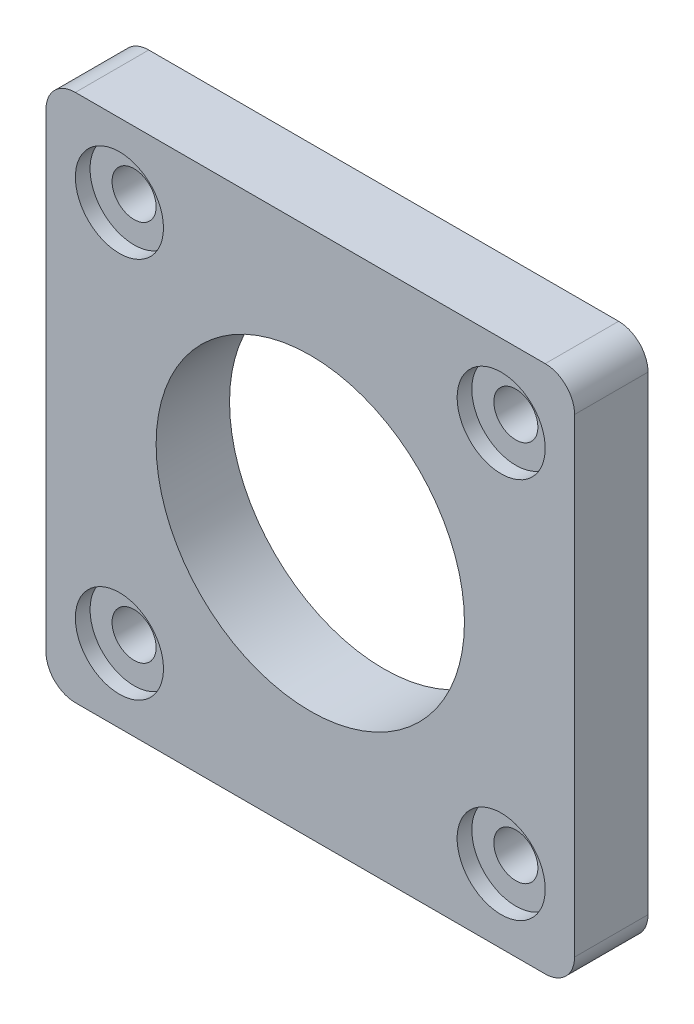
from build123d import *

# Parameters (mm, degrees)
BOSS_EXTRUDE1_DEPTH = 50
SKETCH3_R           = 105
CUT_EXTRUDE1_DEPTH  = 50
SKETCH4_R           = 15
CUT_EXTRUDE3_DEPTH  = 50
SKETCH7_R           = 30
CUT_EXTRUDE4_DEPTH  = 10


with BuildPart() as part:
    # Sketch2 → Boss-Extrude1 (new body)
    with BuildSketch(Plane.XY):
        with BuildLine():
            Line((-160, 180), (160, 180))
            ThreePointArc((160, 180), (174.142135624, 174.142135624), (180, 160))
            Line((180, 160), (180, -160))
            ThreePointArc((180, -160), (174.142135624, -174.142135624), (160, -180))
            Line((160, -180), (-160, -180))
            ThreePointArc((-160, -180), (-174.142135624, -174.142135624), (-180, -160))
            Line((-180, -160), (-180, 160))
            ThreePointArc((-180, 160), (-174.142135624, 174.142135624), (-160, 180))
        make_face()
    extrude(amount=BOSS_EXTRUDE1_DEPTH)

    # Sketch3 → Cut-Extrude1 (cut)
    with BuildSketch(Plane.XY.offset(50)):
        Circle(SKETCH3_R)
    extrude(amount=-CUT_EXTRUDE1_DEPTH, mode=Mode.SUBTRACT)

    # Sketch4 → Cut-Extrude3 (cut)
    with BuildSketch(Plane.XY.offset(50)):
        with Locations((-130, 130)):
            Circle(SKETCH4_R)
        with Locations((-130, -130)):
            Circle(SKETCH4_R)
        with Locations((130, -130)):
            Circle(SKETCH4_R)
        with Locations((130, 130)):
            Circle(SKETCH4_R)
    extrude(amount=-CUT_EXTRUDE3_DEPTH, mode=Mode.SUBTRACT)

    # Sketch7 → Cut-Extrude4 (cut)
    with BuildSketch(Plane.XY.offset(50)):
        with Locations((-130, 130)):
            Circle(SKETCH7_R)
        with Locations((130, 130)):
            Circle(SKETCH7_R)
        with Locations((130, -130)):
            Circle(SKETCH7_R)
        with Locations((-130, -130)):
            Circle(SKETCH7_R)
    extrude(amount=-CUT_EXTRUDE4_DEPTH, mode=Mode.SUBTRACT)


solid = part.part
